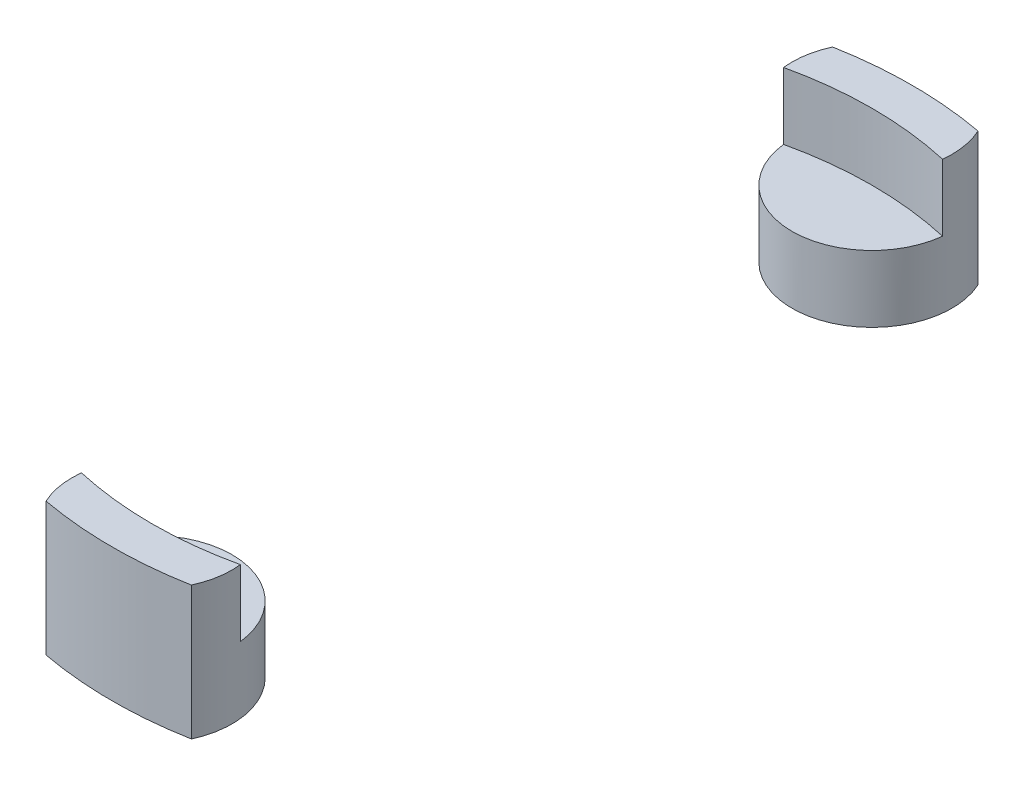
from build123d import *

# Parameters (mm, degrees)
BOSS_EXTRUDE2_DEPTH   = 5
BOSS_EXTRUDE2_2_DEPTH = 5
BOSS_EXTRUDE3_DEPTH   = 2.5


with BuildPart() as part:
    # Sketch2 → Boss-Extrude2 (new body)
    with BuildSketch(Plane(origin=(0, 0, 0), x_dir=(1, 0, 0), z_dir=(0, 1, 0))):
        with BuildLine():
            ThreePointArc((2.727178029, 14.75), (0, 15), (-2.727178029, 14.75))
            ThreePointArc((-2.727178029, 14.75), (-2.962055082, 13.975636094), (-2.98142397, 13.166666667))
            ThreePointArc((-2.98142397, 13.166666667), (0, 13.5), (2.98142397, 13.166666667))
            ThreePointArc((2.98142397, 13.166666667), (2.962055082, 13.975636094), (2.727178029, 14.75))
        make_face()
    extrude(amount=BOSS_EXTRUDE2_DEPTH)



with BuildPart() as body_2:
    # Sketch2 → Boss-Extrude2 2 (new body)
    with BuildSketch(Plane(origin=(0, 0, 0), x_dir=(1, 0, 0), z_dir=(0, 1, 0))):
        with BuildLine():
            ThreePointArc((-2.98142397, -13.166666667), (-2.962055082, -13.975636094), (-2.727178029, -14.75))
            ThreePointArc((-2.727178029, -14.75), (0, -15), (2.727178029, -14.75))
            ThreePointArc((2.727178029, -14.75), (2.962055082, -13.975636094), (2.98142397, -13.166666667))
            ThreePointArc((2.98142397, -13.166666667), (0, -13.5), (-2.98142397, -13.166666667))
        make_face()
    extrude(amount=BOSS_EXTRUDE2_2_DEPTH)


with BuildPart() as part_1:
    add(part.part)

    add(body_2.part)  # Boss-Extrude3 merges body 2
    # Sketch2_6 → Boss-Extrude3 (add)
    with BuildSketch(Plane(origin=(0, 0, 0), x_dir=(1, 0, 0), z_dir=(0, 1, 0))):
        with BuildLine():
            ThreePointArc((2.98142397, 13.166666667), (0, 13.5), (-2.98142397, 13.166666667))
            ThreePointArc((-2.98142397, 13.166666667), (0, 10.5), (2.98142397, 13.166666667))
        make_face()
        with BuildLine():
            ThreePointArc((2.98142397, -13.166666667), (0, -10.5), (-2.98142397, -13.166666667))
            ThreePointArc((-2.98142397, -13.166666667), (0, -13.5), (2.98142397, -13.166666667))
        make_face()
    extrude(amount=BOSS_EXTRUDE3_DEPTH)


solid = part_1.part
